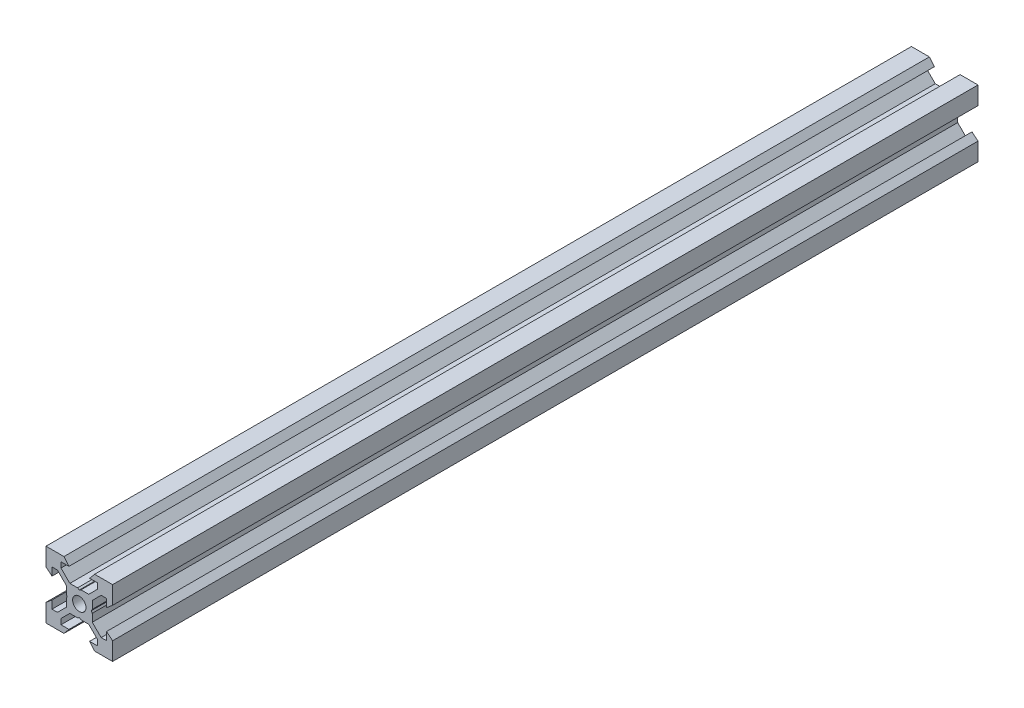
from build123d import *

# Parameters (mm, degrees)
SKETCH1_R           = 2
BOSS_EXTRUDE1_DEPTH = 130


with BuildPart() as part:
    # Sketch1 → Boss-Extrude1 (new body, symmetric)
    with BuildSketch(Plane.XY):
        Polygon((10, 10), (10, 4.610379336), (8.2, 3.1), (8.2, 5.5), (6.560660172, 5.5), (3.9, 2.839339828), (3.9, 0.519615242), (3.6, 0), (3.9, -0.519615242), (3.9, -2.839339828), (6.560660172, -5.5), (8.2, -5.5), (8.2, -3.1), (10, -4.610379336), (10, -10), (4.610379336, -10), (3.1, -8.2), (5.5, -8.2), (5.5, -6.560660172), (2.839339828, -3.9), (0.519615242, -3.9), (0, -3.6), (-0.519615242, -3.9), (-2.839339828, -3.9), (-5.5, -6.560660172), (-5.5, -8.2), (-3.1, -8.2), (-4.610379336, -10), (-10, -10), (-10, -4.610379336), (-8.2, -3.1), (-8.2, -5.5), (-6.560660172, -5.5), (-3.9, -2.839339828), (-3.9, -0.519615242), (-3.6, 0), (-3.9, 0.519615242), (-3.9, 2.839339828), (-6.560660172, 5.5), (-8.2, 5.5), (-8.2, 3.1), (-10, 4.610379336), (-10, 10), (-4.610379336, 10), (-3.1, 8.2), (-5.5, 8.2), (-5.5, 6.560660172), (-2.839339828, 3.9), (-0.519615242, 3.9), (0, 3.6), (0.519615242, 3.9), (2.839339828, 3.9), (5.5, 6.560660172), (5.5, 8.2), (3.1, 8.2), (4.610379336, 10), align=None)
        Circle(SKETCH1_R, mode=Mode.SUBTRACT)
    extrude(amount=BOSS_EXTRUDE1_DEPTH, both=True)


solid = part.part
